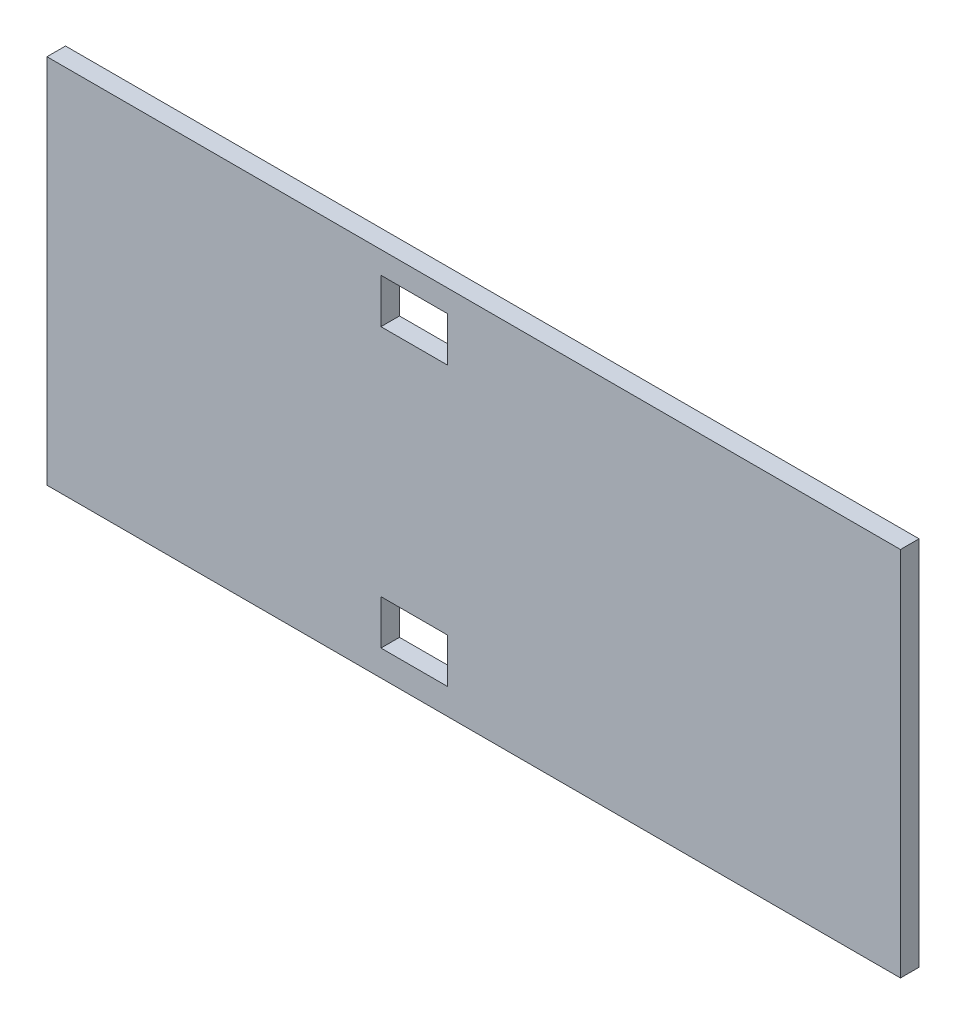
from build123d import *

# Parameters (mm, degrees)
SKETCH1_W           = 292.1
SKETCH1_H           = 127
BOSS_EXTRUDE1_DEPTH = 6.35
SKETCH2_W           = 22.86
SKETCH2_H           = 15.24
CUT_EXTRUDE1_DEPTH  = 6.35
LPATTERN1_COUNT     = 2
LPATTERN1_PITCH     = 95.25


with BuildPart() as part:
    # Sketch1 → Boss-Extrude1 (new body)
    with BuildSketch(Plane.XY):
        with Locations((146.05, 63.5)):
            Rectangle(SKETCH1_W, SKETCH1_H)
    extrude(amount=BOSS_EXTRUDE1_DEPTH)

    # Sketch2 → Cut-Extrude1 (cut)
    with BuildSketch(Plane.XY.offset(6.35)):
        with Locations((125.73, 16.51)):
            Rectangle(SKETCH2_W, SKETCH2_H)
    cut_extrude1 = extrude(amount=-CUT_EXTRUDE1_DEPTH, mode=Mode.SUBTRACT)

    # LPattern1: Cut-Extrude1 ×2
    with Locations(*[(0, i * LPATTERN1_PITCH, 0) for i in range(1, LPATTERN1_COUNT)]):
        add(cut_extrude1, mode=Mode.SUBTRACT)


solid = part.part
